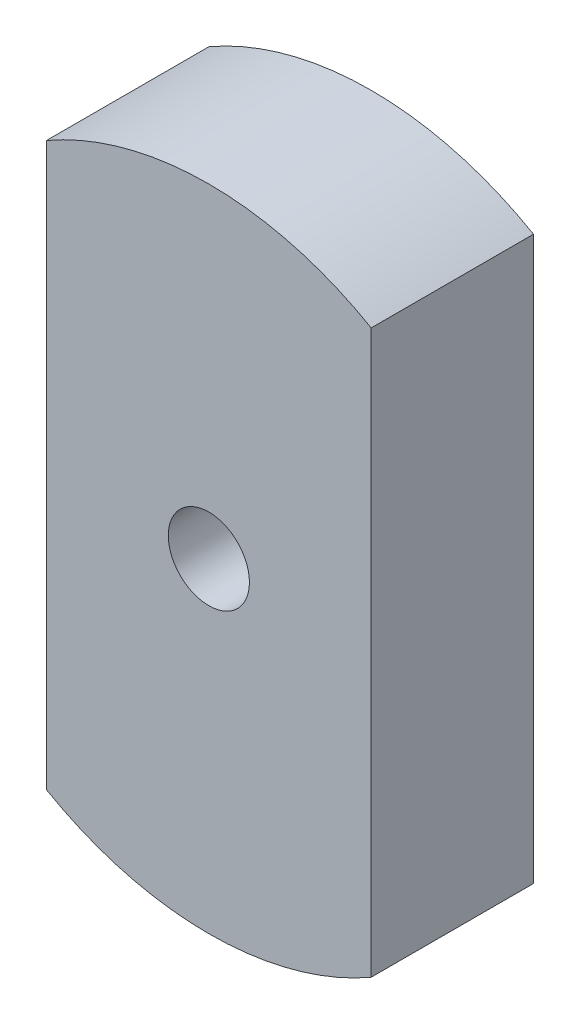
from build123d import *

# Parameters (mm, degrees)
ESQUISSE1_R        = 1.25
BOSS_EXTRU_1_DEPTH = 5


with BuildPart() as part:
    # Esquisse1 → Boss.-Extru.1 (new body)
    with BuildSketch(Plane.XY):
        with BuildLine():
            ThreePointArc((5, 8.660254038), (0, 10), (-5, 8.660254038))
            Line((-5, 8.660254038), (-5, -8.660254038))
            ThreePointArc((-5, -8.660254038), (0, -10), (5, -8.660254038))
            Line((5, -8.660254038), (5, 8.660254038))
        make_face()
        Circle(ESQUISSE1_R, mode=Mode.SUBTRACT)
    extrude(amount=BOSS_EXTRU_1_DEPTH)


solid = part.part
